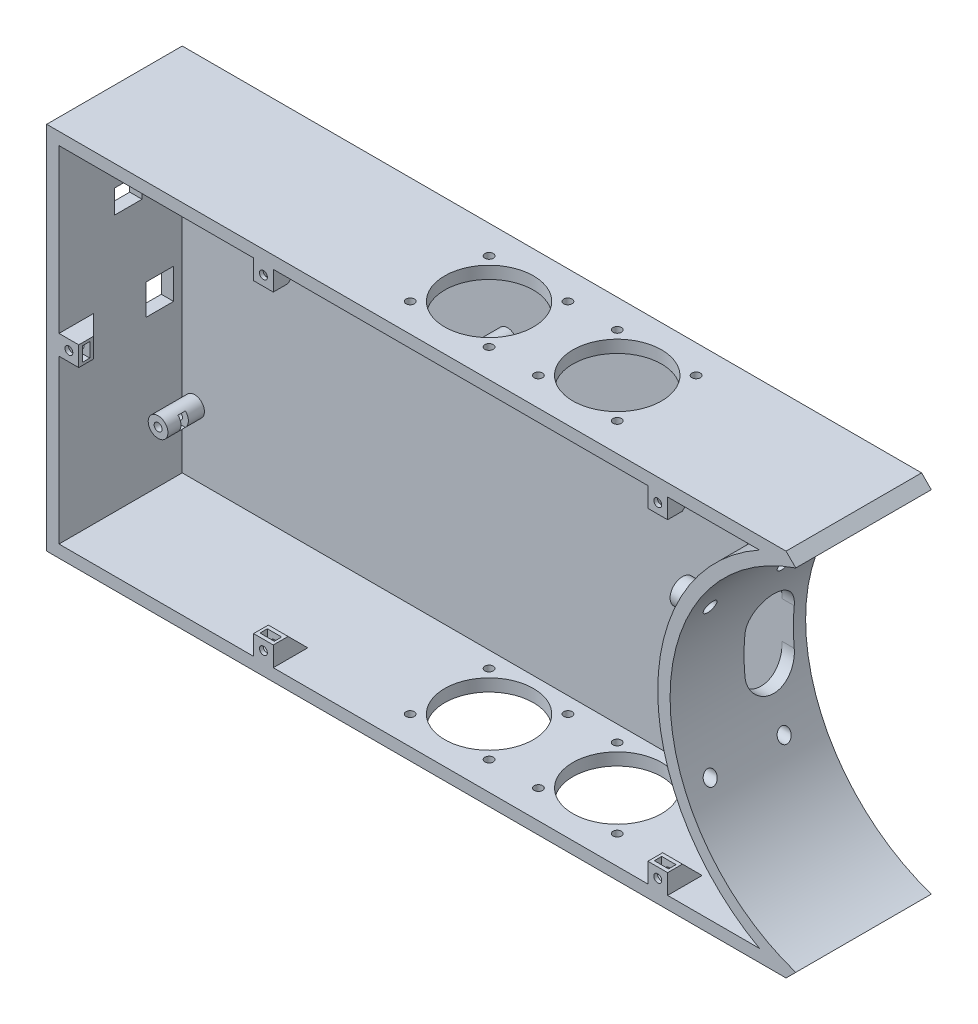
from build123d import *

# Parameters (mm, degrees)
SALIENTE_EXTRUIR1_DEPTH      = 55
CORTAR_EXTRUIR1_DEPTH        = 50
CORTAR_EXTRUIR2_DEPTH        = 82
CROQUIS4_R                   = 2.6
CORTAR_EXTRUIR3_DEPTH        = 82
SALIENTE_EXTRUIR2_REACH      = 266.813
SALIENTE_EXTRUIR2_END_RADIUS = 80
CROQUIS5_R                   = 5
CROQUIS5_R_2                 = 2.6
CROQUIS6_R                   = 1.6
CORTAR_EXTRUIR4_DEPTH        = 82
CROQUIS7_W                   = 11.2
CROQUIS7_H                   = 9.5
CORTAR_EXTRUIR5_DEPTH        = 13
CROQUIS8_W                   = 11.2
CROQUIS8_H                   = 12.4
CORTAR_EXTRUIR6_DEPTH        = 13
SALIENTE_EXTRUIR3_START      = 14.8
CROQUIS9_R                   = 4
CROQUIS9_R_2                 = 1.6
SALIENTE_EXTRUIR3_DEPTH      = 14.8
CROQUIS10_R                  = 1.7
CROQUIS10_R_2                = 18
CORTAR_EXTRUIR7_DEPTH        = 14.8
CORTAR_EXTRUIR8_DEPTH        = 1.5
CORTAR_EXTRUIR8_DEPTH_BACK   = 1.5
SALIENTE_EXTRUIR4_DEPTH      = 4
SALIENTE_EXTRUIR4_DEPTH_BACK = 4
SALIENTE_EXTRUIR5_DEPTH      = 4
CROQUIS13_R                  = 1.6
CORTAR_EXTRUIR9_DEPTH        = 14
CORTAR_EXTRUIR10_DEPTH       = 1.5
CORTAR_EXTRUIR10_DEPTH_BACK  = 1.5


with BuildPart() as part:
    # Croquis1 → Saliente-Extruir1 (new body)
    with BuildSketch(Plane.XY):
        with BuildLine():
            Line((-327.943684306, 75), (-327.943684306, -75))
            Line((-327.943684306, -75), (-27.943684306, -75))
            Line((-27.943684306, -75), (-24, -71.056315694))
            ThreePointArc((-24, -71.056315694), (-75, 0), (-24, 71.056315694))
            Line((-24, 71.056315694), (-27.943684306, 75))
            Line((-27.943684306, 75), (-327.943684306, 75))
        make_face()
    extrude(amount=SALIENTE_EXTRUIR1_DEPTH)

    # Croquis2 → Cortar-Extruir1 (cut)
    with BuildSketch(Plane.XY.offset(55)):
        with BuildLine():
            Line((-38.729833462, 70), (-322.943684306, 70))
            Line((-322.943684306, 70), (-322.943684306, -70))
            Line((-322.943684306, -70), (-38.729833462, -70))
            ThreePointArc((-38.729833462, -70), (-80, 0), (-38.729833462, 70))
        make_face()
    extrude(amount=-CORTAR_EXTRUIR1_DEPTH, mode=Mode.SUBTRACT)

    # Croquis3 → Cortar-Extruir2 (cut)
    with BuildSketch(Plane(origin=(0, 0, 0), x_dir=(0, 0, -1), z_dir=(1, 0, 0))):
        with BuildLine():
            Line((-5, 7.5), (-5, -7.5))
            ThreePointArc((-5, -7.5), (-15, -17.5), (-25, -7.5))
            Line((-25, -7.5), (-25, 7.5))
            ThreePointArc((-25, 7.5), (-15, 17.5), (-5, 7.5))
        make_face()
    extrude(amount=-CORTAR_EXTRUIR2_DEPTH, mode=Mode.SUBTRACT)

    # Croquis4 → Cortar-Extruir3 (cut)
    with BuildSketch(Plane(origin=(0, 0, 0), x_dir=(0, 0, -1), z_dir=(1, 0, 0))):
        with Locations((-45, -30)):
            Circle(CROQUIS4_R)
        with Locations((-15, -30)):
            Circle(CROQUIS4_R)
        with Locations((-15, 30)):
            Circle(CROQUIS4_R)
        with Locations((-45, 30)):
            Circle(CROQUIS4_R)
    extrude(amount=-CORTAR_EXTRUIR3_DEPTH, mode=Mode.SUBTRACT)

    # Saliente-Extruir2: up to this cylinder (the profile starts outside it)
    saliente_extruir2_end = Plane(origin=(0, 0, 25.141421), z_dir=(0, 0, 1)) * Cylinder(SALIENTE_EXTRUIR2_END_RADIUS, 724.626, mode=Mode.PRIVATE)
    # Croquis5 → Saliente-Extruir2 (add, up to the surface)
    with BuildSketch(Plane.ZY.offset(80), mode=Mode.PRIVATE) as saliente_extruir2_sk1:
        with Locations((45, 30)):
            Circle(CROQUIS5_R)
        with Locations((45, 30)):
            Circle(CROQUIS5_R_2, mode=Mode.SUBTRACT)
    saliente_extruir2_tool1 = extrude(saliente_extruir2_sk1.sketch, amount=-SALIENTE_EXTRUIR2_REACH, mode=Mode.PRIVATE) - saliente_extruir2_end
    add(saliente_extruir2_tool1.solids().sort_by_distance((-80, 30, 40.141421))[0])
    # Croquis5 → Saliente-Extruir2 (add, up to the surface)
    with BuildSketch(Plane.ZY.offset(80), mode=Mode.PRIVATE) as saliente_extruir2_sk2:
        with Locations((15, 30)):
            Circle(CROQUIS5_R)
        with Locations((15, 30)):
            Circle(CROQUIS5_R_2, mode=Mode.SUBTRACT)
    saliente_extruir2_tool2 = extrude(saliente_extruir2_sk2.sketch, amount=-SALIENTE_EXTRUIR2_REACH, mode=Mode.PRIVATE) - saliente_extruir2_end
    add(saliente_extruir2_tool2.solids().sort_by_distance((-80, 30, 10.141421))[0])
    # Croquis5 → Saliente-Extruir2 (add, up to the surface)
    with BuildSketch(Plane.ZY.offset(80), mode=Mode.PRIVATE) as saliente_extruir2_sk3:
        with Locations((45, -30)):
            Circle(CROQUIS5_R)
        with Locations((45, -30)):
            Circle(CROQUIS5_R_2, mode=Mode.SUBTRACT)
    saliente_extruir2_tool3 = extrude(saliente_extruir2_sk3.sketch, amount=-SALIENTE_EXTRUIR2_REACH, mode=Mode.PRIVATE) - saliente_extruir2_end
    add(saliente_extruir2_tool3.solids().sort_by_distance((-80, -30, 40.141421))[0])
    # Croquis5 → Saliente-Extruir2 (add, up to the surface)
    with BuildSketch(Plane.ZY.offset(80), mode=Mode.PRIVATE) as saliente_extruir2_sk4:
        with Locations((15, -30)):
            Circle(CROQUIS5_R)
        with Locations((15, -30)):
            Circle(CROQUIS5_R_2, mode=Mode.SUBTRACT)
    saliente_extruir2_tool4 = extrude(saliente_extruir2_sk4.sketch, amount=-SALIENTE_EXTRUIR2_REACH, mode=Mode.PRIVATE) - saliente_extruir2_end
    add(saliente_extruir2_tool4.solids().sort_by_distance((-80, -30, 10.141421))[0])

    # Croquis6 → Cortar-Extruir4 (cut)
    with BuildSketch(Plane.XY.offset(5)):
        with Locations((-302.943684306, 44)):
            Circle(CROQUIS6_R)
        with Locations((-317.943684306, -44)):
            Circle(CROQUIS6_R)
        with Locations((-190.943684306, 43)):
            Circle(CROQUIS6_R)
        with Locations((-102.943684306, 43)):
            Circle(CROQUIS6_R)
        with Locations((-102.943684306, -43)):
            Circle(CROQUIS6_R)
    extrude(amount=-CORTAR_EXTRUIR4_DEPTH, mode=Mode.SUBTRACT)

    # Croquis7 → Cortar-Extruir5 (cut)
    with BuildSketch(Plane.ZY.offset(327.943684306)):
        with Locations((26.9, 39.05)):
            Rectangle(CROQUIS7_W, CROQUIS7_H)
    extrude(amount=-CORTAR_EXTRUIR5_DEPTH, mode=Mode.SUBTRACT)

    # Croquis8 → Cortar-Extruir6 (cut)
    with BuildSketch(Plane.ZY.offset(327.943684306)):
        with Locations((14.1, -1.8)):
            Rectangle(CROQUIS8_W, CROQUIS8_H)
    extrude(amount=-CORTAR_EXTRUIR6_DEPTH, mode=Mode.SUBTRACT)

    # Croquis9 → Saliente-Extruir3 (add)
    # profile 1 of 5: a face of its own
    with BuildSketch(Plane.XY.offset(5).offset(SALIENTE_EXTRUIR3_START)):
        with Locations((-302.943684306, 44)):
            Circle(CROQUIS9_R)
        with Locations((-302.943684306, 44)):
            Circle(CROQUIS9_R_2, mode=Mode.SUBTRACT)
    # profile 2 of 5: a face of its own
    with BuildSketch(Plane.XY.offset(5).offset(SALIENTE_EXTRUIR3_START)):
        with Locations((-317.943684306, -44)):
            Circle(CROQUIS9_R)
        with Locations((-317.943684306, -44)):
            Circle(CROQUIS9_R_2, mode=Mode.SUBTRACT)
    # profile 3 of 5: a face of its own
    with BuildSketch(Plane.XY.offset(5).offset(SALIENTE_EXTRUIR3_START)):
        with Locations((-190.943684306, 43)):
            Circle(CROQUIS9_R)
        with Locations((-190.943684306, 43)):
            Circle(CROQUIS9_R_2, mode=Mode.SUBTRACT)
    # profile 4 of 5: a face of its own
    with BuildSketch(Plane.XY.offset(5).offset(SALIENTE_EXTRUIR3_START)):
        with Locations((-102.943684306, 43)):
            Circle(CROQUIS9_R)
        with Locations((-102.943684306, 43)):
            Circle(CROQUIS9_R_2, mode=Mode.SUBTRACT)
    # profile 5 of 5: a face of its own
    with BuildSketch(Plane.XY.offset(5).offset(SALIENTE_EXTRUIR3_START)):
        with Locations((-102.943684306, -43)):
            Circle(CROQUIS9_R)
        with Locations((-102.943684306, -43)):
            Circle(CROQUIS9_R_2, mode=Mode.SUBTRACT)
    extrude(amount=-SALIENTE_EXTRUIR3_DEPTH)

    # Croquis10 → Cortar-Extruir7 (cut)
    with BuildSketch(Plane.XZ.offset(75)):
        with Locations((-191.943684306, 43.5)):
            Circle(CROQUIS10_R)
        with Locations((-159.943684306, 43.5)):
            Circle(CROQUIS10_R)
        with Locations((-191.943684306, 11.5)):
            Circle(CROQUIS10_R)
        with Locations((-159.943684306, 11.5)):
            Circle(CROQUIS10_R)
        with Locations((-139.943684306, 43.5)):
            Circle(CROQUIS10_R)
        with Locations((-107.943684306, 43.5)):
            Circle(CROQUIS10_R)
        with Locations((-139.943684306, 11.5)):
            Circle(CROQUIS10_R)
        with Locations((-107.943684306, 11.5)):
            Circle(CROQUIS10_R)
        with Locations((-175.943684306, 27.5)):
            Circle(CROQUIS10_R_2)
        with Locations((-123.943684306, 27.5)):
            Circle(CROQUIS10_R_2)
    cortar_extruir7 = extrude(amount=-CORTAR_EXTRUIR7_DEPTH, mode=Mode.SUBTRACT)

    # Simetría1: Cortar-Extruir7 across plane
    add(cortar_extruir7.mirror(Plane.ZX), mode=Mode.SUBTRACT)

    # Croquis11 → Cortar-Extruir8 (cut, two sides: drawn at the far end of the back side and taken through both)
    with BuildSketch(Plane.XY.offset(13).offset(-CORTAR_EXTRUIR8_DEPTH_BACK)):
        Polygon((-301.268684306, 46.901185103), (-296.596208082, 46.901185103), (-296.596208082, 41.098814897), (-301.268684306, 41.098814897), (-304.618684306, 41.098814897), (-306.293684306, 44), (-304.618684306, 46.901185103), align=None)
        Polygon((-316.268684306, -41.098814897), (-319.618684306, -41.098814897), (-321.293684306, -44), (-319.618684306, -46.901185103), (-316.268684306, -46.901185103), (-310.721620957, -46.901185103), (-310.721620957, -41.098814897), align=None)
        Polygon((-187.593684306, 43), (-189.268684306, 45.901185103), (-192.618684306, 45.901185103), (-196.683445183, 45.901185103), (-196.683445183, 40.098814897), (-192.618684306, 40.098814897), (-189.268684306, 40.098814897), align=None)
        Polygon((-99.593684306, 43), (-101.268684306, 45.901185103), (-104.618684306, 45.901185103), (-110.770583293, 45.901185103), (-110.770583293, 40.098814897), (-104.618684306, 40.098814897), (-101.268684306, 40.098814897), align=None)
        Polygon((-99.593684306, -43), (-101.268684306, -40.098814897), (-104.618684306, -40.098814897), (-109.047231964, -40.098814897), (-109.167846689, -45.901185103), (-104.618684306, -45.901185103), (-101.268684306, -45.901185103), align=None)
    extrude(amount=CORTAR_EXTRUIR8_DEPTH + CORTAR_EXTRUIR8_DEPTH_BACK, mode=Mode.SUBTRACT)

    # Croquis12 → Saliente-Extruir4 (add, two sides: drawn at the far end of the back side and taken through both)
    with BuildSketch(Plane(origin=(0, 0, 0), x_dir=(1, 0, 0), z_dir=(0, 1, 0)).offset(-SALIENTE_EXTRUIR4_DEPTH_BACK)):
        Polygon((-322.943684306, -41), (-322.943684306, -55), (-314.943684306, -55), (-314.943684306, -49), align=None)
    extrude(amount=SALIENTE_EXTRUIR4_DEPTH + SALIENTE_EXTRUIR4_DEPTH_BACK)

    # Croquis14 → Saliente-Extruir5 (add, symmetric)
    with BuildSketch(Plane.ZY.offset(80)):
        Polygon((55, 70), (55, 62), (49, 62), (41, 70), align=None)
        Polygon((55, -70), (55, -62), (49, -62), (41, -70), align=None)
    saliente_extruir5 = extrude(amount=SALIENTE_EXTRUIR5_DEPTH, both=True)

    # Croquis13 → Cortar-Extruir9 (cut)
    with BuildSketch(Plane.XY.offset(55)):
        with Locations((-318.943684306, 0)):
            Circle(CROQUIS13_R)
        with Locations((-80, -66)):
            Circle(CROQUIS13_R)
        with Locations((-80, 66)):
            Circle(CROQUIS13_R)
    cortar_extruir9 = extrude(amount=-CORTAR_EXTRUIR9_DEPTH, mode=Mode.SUBTRACT)

    # Simetría2: Saliente-Extruir5, Cortar-Extruir9 across plane
    add(saliente_extruir5.mirror(Plane.ZY.offset(160)))
    add(cortar_extruir9.mirror(Plane.ZY.offset(160)), mode=Mode.SUBTRACT)

    # Croquis17 → Cortar-Extruir10 (cut, two sides: drawn at the far end of the back side and taken through both)
    with BuildSketch(Plane.XY.offset(52).offset(-CORTAR_EXTRUIR10_DEPTH_BACK)):
        Polygon((-317.268684306, 2.901185103), (-320.618684306, 2.901185103), (-322.293684306, 0), (-320.618684306, -2.901185103), (-317.268684306, -2.901185103), (-310.618684306, -2.901185103), (-310.618684306, 2.901185103), align=None)
        Polygon((-242.901185103, -64.325), (-242.901185103, -67.675), (-240, -69.35), (-237.098814897, -67.675), (-237.098814897, -64.325), (-237.098814897, -57.675), (-242.901185103, -57.675), align=None)
        Polygon((-82.901185103, -64.325), (-82.901185103, -67.675), (-80, -69.35), (-77.098814897, -67.675), (-77.098814897, -64.325), (-77.098814897, -57.675), (-82.901185103, -57.675), align=None)
        Polygon((-77.098814897, 64.325), (-77.098814897, 67.675), (-80, 69.35), (-82.901185103, 67.675), (-82.901185103, 64.325), (-82.901185103, 57.675), (-76.887318252, 57.675), align=None)
        Polygon((-237.098814897, 64.325), (-237.098814897, 67.675), (-240, 69.35), (-242.901185103, 67.675), (-242.901185103, 64.325), (-242.901185103, 57.675), (-237.098814897, 57.675), align=None)
    extrude(amount=CORTAR_EXTRUIR10_DEPTH + CORTAR_EXTRUIR10_DEPTH_BACK, mode=Mode.SUBTRACT)


solid = part.part
